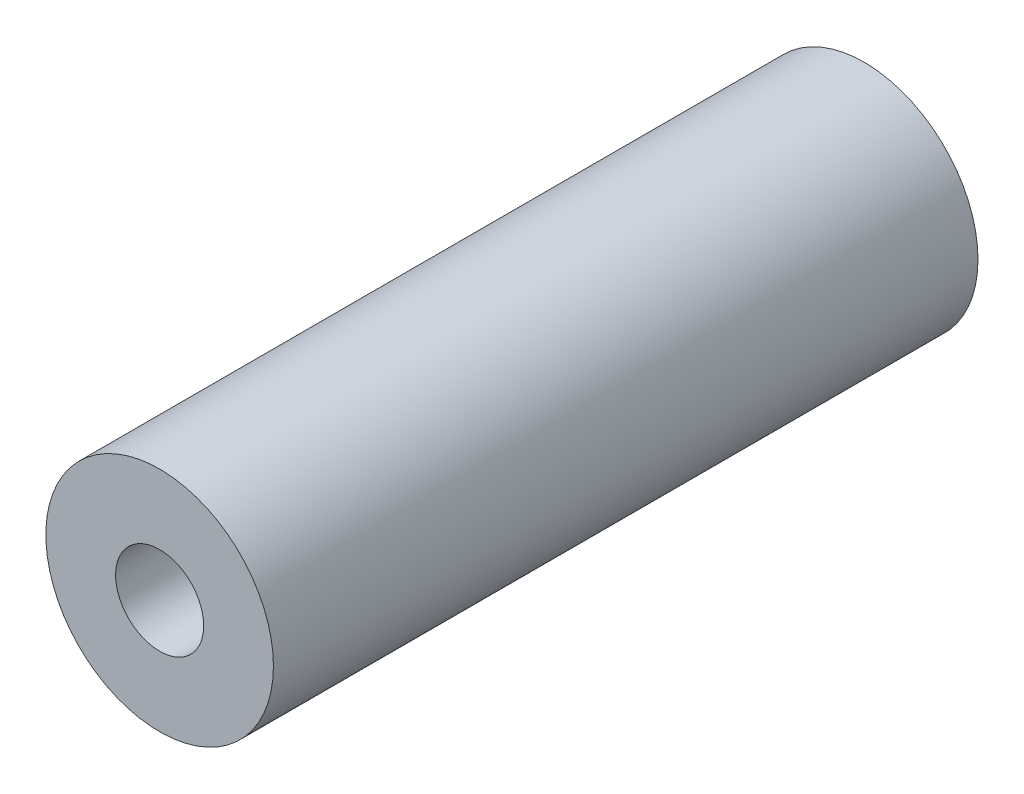
from build123d import *

# Parameters (mm, degrees)
SKETCH1_R           = 16.4084
BOSS_EXTRUDE1_DEPTH = 101.6


with BuildPart() as part:
    # Sketch1 → Boss-Extrude1 (new body)
    with BuildSketch(Plane.XY):
        with Locations((-492.127121378, 1432.787310137)):
            Circle(SKETCH1_R)
    extrude(amount=BOSS_EXTRUDE1_DEPTH)

    # Sketch3 → Cut-Revolve1 (revolve, cut)
    with BuildSketch(Plane(origin=(-492.127121378, 0, 0), x_dir=(0, 0, -1), z_dir=(1, 0, 0))):
        Polygon((-91.44, 1445.385710137), (-10.16, 1445.385710137), (-10.16, 1439.137310137), (0, 1439.137310137), (0, 1432.787310137), (-101.6, 1432.787310137), (-101.6, 1439.137310137), (-91.44, 1439.137310137), align=None)
    revolve(axis=Axis((-492.127121378, 1432.787310137, 101.6), (0, 0, -1)), mode=Mode.SUBTRACT)


solid = part.part
